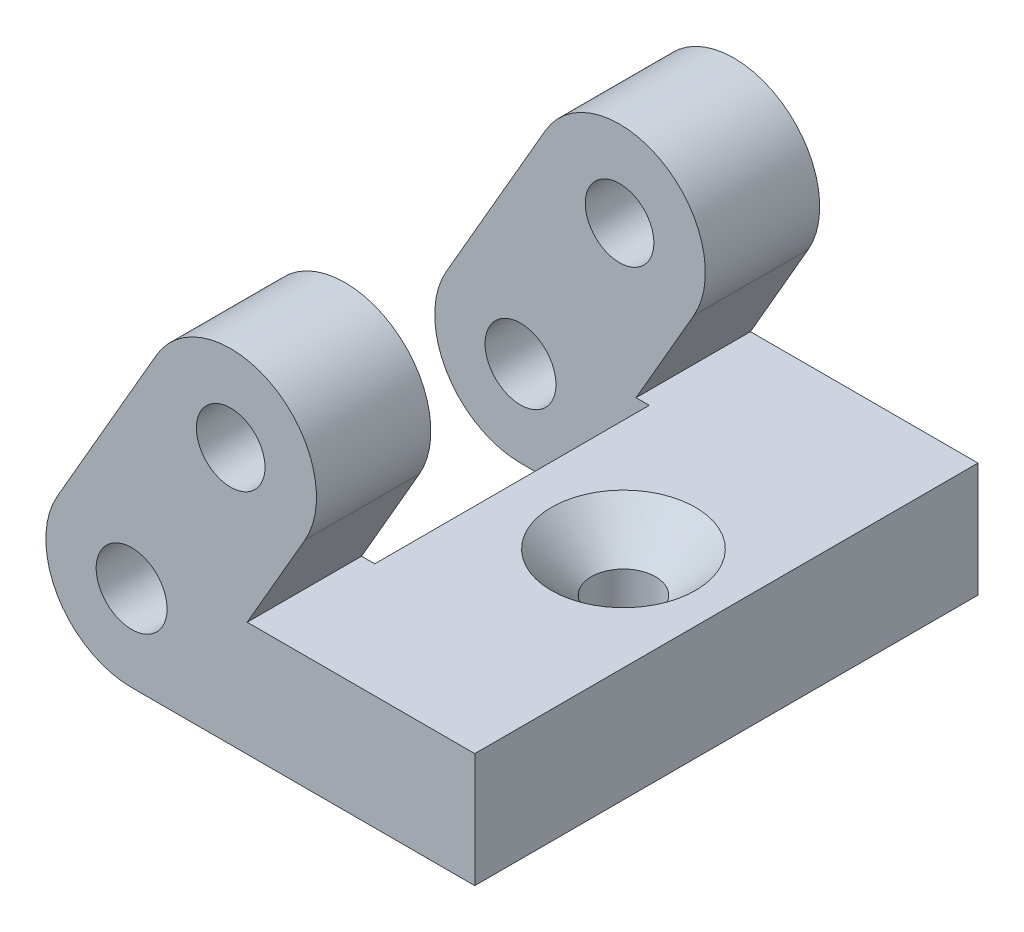
from build123d import *

# Parameters (mm, degrees)
SKETCH1_R                                       = 1.55
SKETCH1_R_2                                     = 1.5
BOSS_EXTRUDE1_DEPTH                             = 11
CUT_EXTRUDE1_DEPTH                              = 6
CSK_FOR_M3_FLAT_HEAD_MACHINE_SCREW1_D           = 2.8
CSK_FOR_M3_FLAT_HEAD_MACHINE_SCREW1_DEPTH       = 10
CSK_FOR_M3_FLAT_HEAD_MACHINE_SCREW1_CSINK_D     = 6.3
CSK_FOR_M3_FLAT_HEAD_MACHINE_SCREW1_CSINK_ANGLE = 90
CSK_FOR_M3_FLAT_HEAD_MACHINE_SCREW1_TIP         = 0.841204867
FILLET1_R                                       = 1


with BuildPart() as part:
    # Sketch1 → Boss-Extrude1 (new body, symmetric)
    with BuildSketch(Plane.XY):
        with BuildLine():
            Line((1.082531755, 9.375), (-3.247595264, 1.875))
            ThreePointArc((-3.247595264, 1.875), (-3.247595264, -1.875), (0, -3.75))
            Line((0, -3.75), (15, -3.75))
            Line((15, -3.75), (15, 1.25))
            Line((15, 1.25), (5.051814855, 1.25))
            Line((5.051814855, 1.25), (7.577722283, 5.625))
            ThreePointArc((7.577722283, 5.625), (6.205127019, 10.747595264), (1.082531755, 9.375))
        make_face()
        Circle(SKETCH1_R, mode=Mode.SUBTRACT)
        with Locations((4.330127019, 7.5)):
            Circle(SKETCH1_R_2, mode=Mode.SUBTRACT)
    extrude(amount=BOSS_EXTRUDE1_DEPTH, both=True)

    # Sketch5 → Cut-Extrude1 (cut, symmetric)
    with BuildSketch(Plane.XY):
        with BuildLine():
            Line((-3.680607966, 2.125), (5.998626937, 18.88992663))
            Line((5.998626937, 18.88992663), (13.359842869, 14.63992663))
            Line((13.359842869, 14.63992663), (3.680607966, -2.125))
            ThreePointArc((3.680607966, -2.125), (-2.125, -3.680607966), (-3.680607966, 2.125))
        make_face()
    extrude(amount=CUT_EXTRUDE1_DEPTH, both=True, mode=Mode.SUBTRACT)

    # CSK for M3 Flat Head Machine Screw1
    with Locations(Plane(origin=(0, 1.25, 0), x_dir=(1, 0, 0), z_dir=(0, 1, 0))):
        with Locations((10.5, 0)):
            CounterSinkHole(CSK_FOR_M3_FLAT_HEAD_MACHINE_SCREW1_D / 2, CSK_FOR_M3_FLAT_HEAD_MACHINE_SCREW1_CSINK_D / 2, depth=CSK_FOR_M3_FLAT_HEAD_MACHINE_SCREW1_DEPTH, counter_sink_angle=CSK_FOR_M3_FLAT_HEAD_MACHINE_SCREW1_CSINK_ANGLE)
            with Locations((0, 0, -(CSK_FOR_M3_FLAT_HEAD_MACHINE_SCREW1_DEPTH + CSK_FOR_M3_FLAT_HEAD_MACHINE_SCREW1_TIP / 2))):  # 118° drill point
                Cone(0, CSK_FOR_M3_FLAT_HEAD_MACHINE_SCREW1_D / 2, CSK_FOR_M3_FLAT_HEAD_MACHINE_SCREW1_TIP, mode=Mode.SUBTRACT)

    # Fillet1
    fillet1_edges = [part.edges().sort_by_distance(p)[0] for p in [
        (2, -3.75, 0),
    ]]
    fillet(fillet1_edges, radius=FILLET1_R)


solid = part.part
